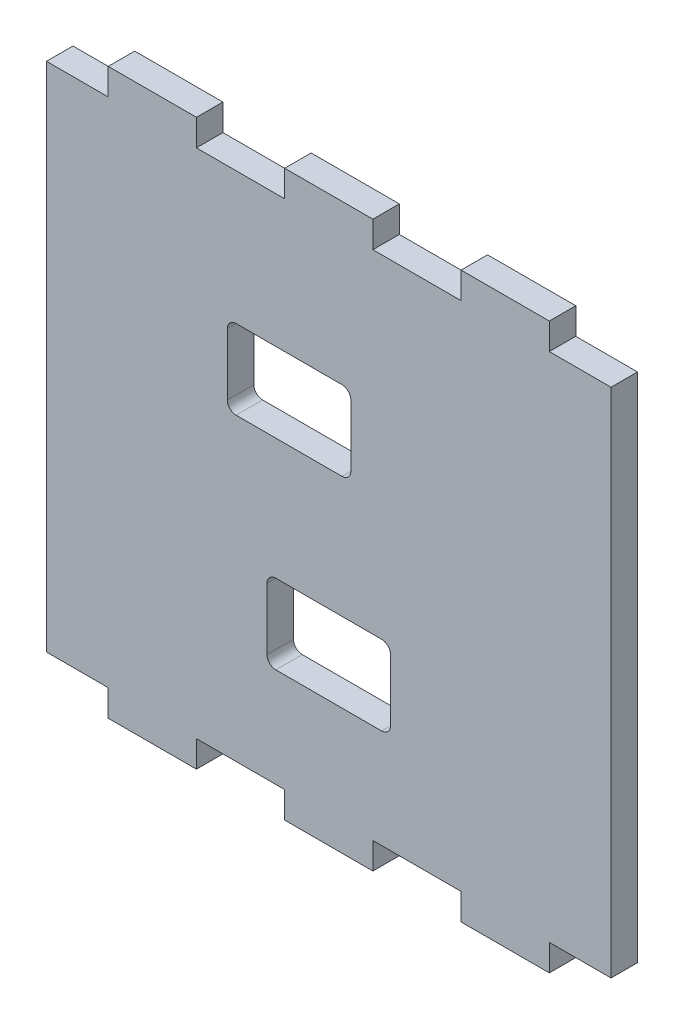
from build123d import *

# Parameters (mm, degrees)
SALIENTE_EXTRUIR1_DEPTH = 3
CROQUIS2_W              = 14
CROQUIS2_H              = 9
CORTAR_EXTRUIR1_DEPTH   = 3
REDONDEO1_R             = 1


with BuildPart() as part:
    # Croquis1 → Saliente-Extruir1 (new body)
    with BuildSketch(Plane.XY):
        Polygon((-32, 29), (-25, 29), (-25, 32), (-15, 32), (-15, 29), (-5, 29), (-5, 32), (5, 32), (5, 29), (15, 29), (15, 32), (25, 32), (25, 29), (32, 29), (32, -29), (25, -29), (25, -32), (15, -32), (15, -29), (5, -29), (5, -32), (-5, -32), (-5, -29), (-15, -29), (-15, -32), (-25, -32), (-25, -29), (-32, -29), align=None)
    extrude(amount=SALIENTE_EXTRUIR1_DEPTH)

    # Croquis2 → Cortar-Extruir1 (cut)
    with BuildSketch(Plane.XY.offset(3)):
        with Locations((0, -13.25)):
            Rectangle(CROQUIS2_W, CROQUIS2_H)
        with Locations((-4.5, 9.5)):
            Rectangle(CROQUIS2_W, CROQUIS2_H)
    extrude(amount=-CORTAR_EXTRUIR1_DEPTH, mode=Mode.SUBTRACT)

    # Redondeo1
    redondeo1_edges = [part.edges().sort_by_distance(p)[0] for p in [
        (7, -8.75, 1.5),
        (7, -17.75, 1.5),
        (-7, -17.75, 1.5),
        (-7, -8.75, 1.5),
        (2.5, 14, 1.5),
        (2.5, 5, 1.5),
        (-11.5, 5, 1.5),
        (-11.5, 14, 1.5),
    ]]
    fillet(redondeo1_edges, radius=REDONDEO1_R)


solid = part.part
